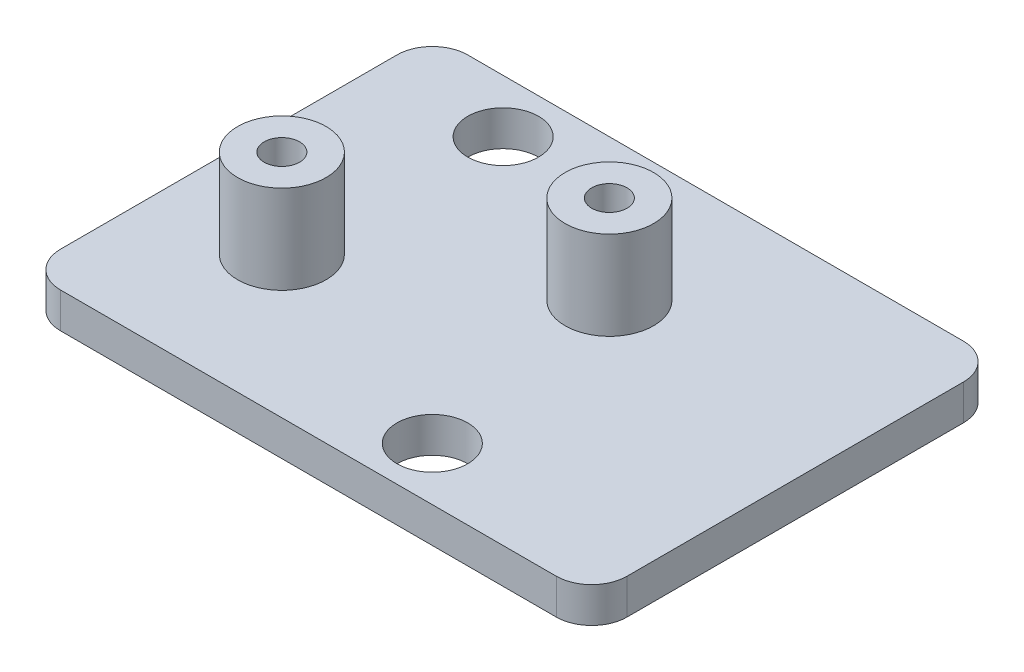
from build123d import *

# Parameters (mm, degrees)
SKETCH_1_W          = 32
SKETCH_1_H          = 23
EXTRUDE_1_DEPTH     = 2
SKETCH_4_R          = 2.5
EXTRUDE_2_DEPTH     = 5
SKETCH_5_R          = 1
CUT_EXTRUDE_1_DEPTH = 8
SKETCH_7_R          = 2
CUT_EXTRUDE_2_DEPTH = 3
FILLET_1_R          = 2
FILLET_2_R          = 2
FILLET_3_R          = 2
FILLET_4_R          = 2


with BuildPart() as part:
    # Эскиз1 → Бобышка-Вытянуть1 (new body)
    with BuildSketch(Plane(origin=(0, 0, 0), x_dir=(1, 0, 0), z_dir=(0, 1, 0))):
        with Locations((16, -11.5)):
            Rectangle(SKETCH_1_W, SKETCH_1_H)
    extrude(amount=EXTRUDE_1_DEPTH)

    # Эскиз4 → Бобышка-Вытянуть2 (add)
    with BuildSketch(Plane(origin=(0, 2, 0), x_dir=(1, 0, 0), z_dir=(0, 1, 0))):
        with Locations((18, -8)):
            Circle(SKETCH_4_R)
        with Locations((6.5, -15)):
            Circle(SKETCH_4_R)
    extrude(amount=EXTRUDE_2_DEPTH)

    # Эскиз5 → Вырез-Вытянуть1 (cut, through all)
    with BuildSketch(Plane(origin=(0, 7, 0), x_dir=(1, 0, 0), z_dir=(0, 1, 0))):
        with Locations((6.5, -15)):
            Circle(SKETCH_5_R)
        with Locations((18, -8)):
            Circle(SKETCH_5_R)
    extrude(amount=-CUT_EXTRUDE_1_DEPTH, mode=Mode.SUBTRACT)

    # Эскиз7 → Вырез-Вытянуть2 (cut, through all)
    with BuildSketch(Plane(origin=(0, 2, 0), x_dir=(1, 0, 0), z_dir=(0, 1, 0))):
        with Locations((7, -3)):
            Circle(SKETCH_7_R)
        with Locations((20, -20)):
            Circle(SKETCH_7_R)
    extrude(amount=-CUT_EXTRUDE_2_DEPTH, mode=Mode.SUBTRACT)

    # Скругление1
    fillet_1_edges = [part.edges().sort_by_distance(p)[0] for p in [
        (0, 1, 0),
    ]]
    fillet(fillet_1_edges, radius=FILLET_1_R)

    # Скругление2
    fillet_2_edges = [part.edges().sort_by_distance(p)[0] for p in [
        (0, 1, 23),
    ]]
    fillet(fillet_2_edges, radius=FILLET_2_R)

    # Скругление3
    fillet_3_edges = [part.edges().sort_by_distance(p)[0] for p in [
        (32, 1, 23),
    ]]
    fillet(fillet_3_edges, radius=FILLET_3_R)

    # Скругление4
    fillet_4_edges = [part.edges().sort_by_distance(p)[0] for p in [
        (32, 1, 0),
    ]]
    fillet(fillet_4_edges, radius=FILLET_4_R)


solid = part.part
